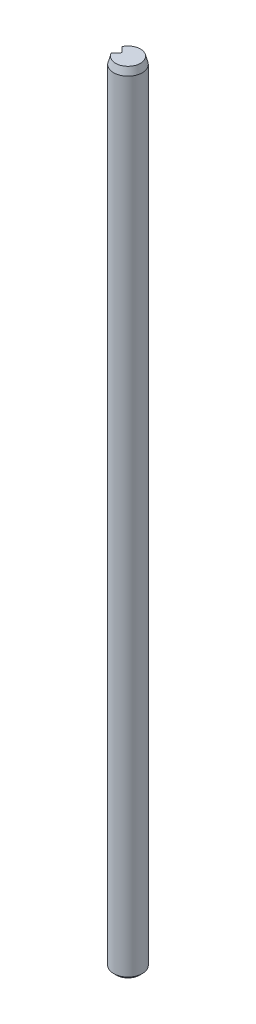
from build123d import *

# Parameters (mm, degrees)
SKETCH1_R           = 1
BOSS_EXTRUDE1_DEPTH = 55
CUT_EXTRUDE1_DEPTH  = 56
FILLET1_R           = 0.1
CHAMFER1_SIZE       = 0.5
CHAMFER1_SIZE2      = 0.133974596
CHAMFER2_SIZE       = 0.2


with BuildPart() as part:
    # Sketch1 → Boss-Extrude1 (new body)
    with BuildSketch(Plane(origin=(0, 0, 0), x_dir=(1, 0, 0), z_dir=(0, 1, 0))):
        Circle(SKETCH1_R)
    extrude(amount=BOSS_EXTRUDE1_DEPTH)

    # Sketch2 → Cut-Extrude1 (cut, through all)
    with BuildSketch(Plane(origin=(0, 55, 0), x_dir=(1, 0, 0), z_dir=(0, 1, 0))):
        with BuildLine():
            Line((-0.878280893, 0.478145033), (-0.40013586, 0))
            Line((-0.40013586, 0), (-0.878280893, -0.478145033))
            ThreePointArc((-0.878280893, -0.478145033), (-1, 0), (-0.878280893, 0.478145033))
        make_face()
    extrude(amount=-CUT_EXTRUDE1_DEPTH, mode=Mode.SUBTRACT)

    # Fillet1
    fillet1_edges = [part.edges().sort_by_distance(p)[0] for p in [
        (-0.40013586, 27.5, 0),
    ]]
    fillet(fillet1_edges, radius=FILLET1_R)

    # Chamfer1
    chamfer1_edges = [part.edges().sort_by_distance(p)[0] for p in [
        (1, 55, 0),
    ]]
    chamfer1_side = [part.faces().sort_by_distance(p)[0] for p in [
        (1, 27.5, 0),
    ]]
    chamfer(chamfer1_edges, length=CHAMFER1_SIZE, length2=CHAMFER1_SIZE2, reference=chamfer1_side[0])

    # Chamfer2
    chamfer2_edges = [part.edges().sort_by_distance(p)[0] for p in [
        (1, 0, 0),
    ]]
    chamfer(chamfer2_edges, length=CHAMFER2_SIZE)


solid = part.part
